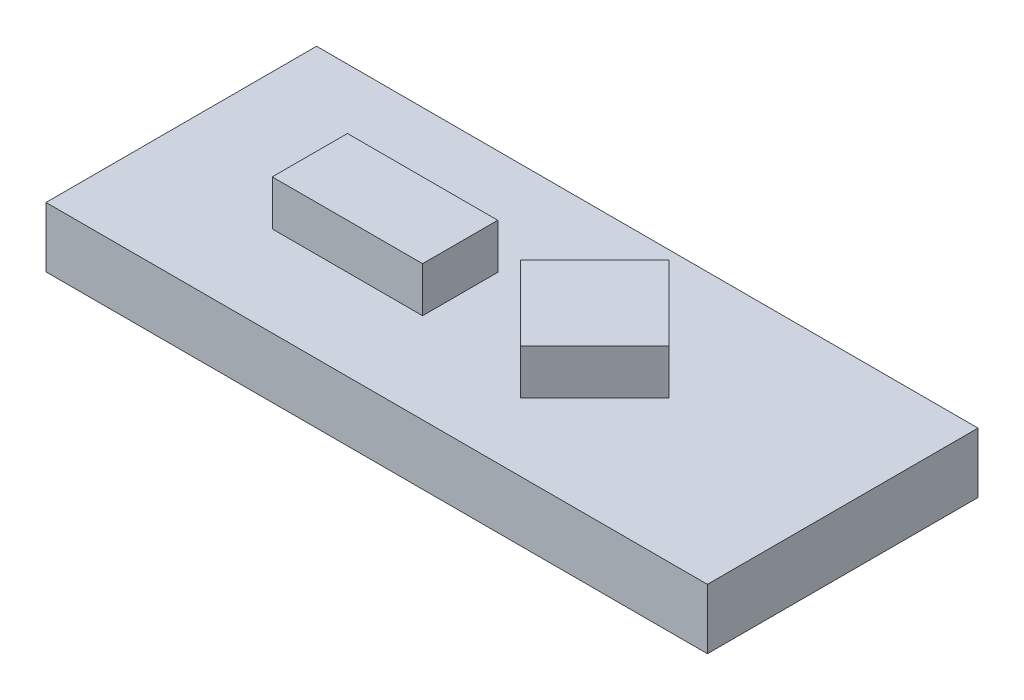
from build123d import *

# Parameters (mm, degrees)
SKETCH1_W           = 44
SKETCH1_H           = 18
BOSS_EXTRUDE1_DEPTH = 4
SKETCH2_W           = 10
SKETCH2_H           = 5
BOSS_EXTRUDE2_DEPTH = 3


with BuildPart() as part:
    # Sketch1 → Boss-Extrude1 (new body)
    with BuildSketch(Plane(origin=(0, 0, 0), x_dir=(1, 0, 0), z_dir=(0, 1, 0))):
        with Locations((-1.926267281, 3.875576037)):
            Rectangle(SKETCH1_W, SKETCH1_H)
    extrude(amount=BOSS_EXTRUDE1_DEPTH)

    # Sketch2 → Boss-Extrude2 (add)
    with BuildSketch(Plane(origin=(0, 4, 0), x_dir=(1, 0, 0), z_dir=(0, 1, 0))):
        with Locations((-9.873666519, 3.375576037)):
            Rectangle(SKETCH2_W, SKETCH2_H)
        Polygon((-1.825762218, 4.325323505), (3.123985251, -0.624423963), (8.073732719, 4.325323505), (3.123985251, 9.275070973), align=None)
    extrude(amount=BOSS_EXTRUDE2_DEPTH)


solid = part.part
